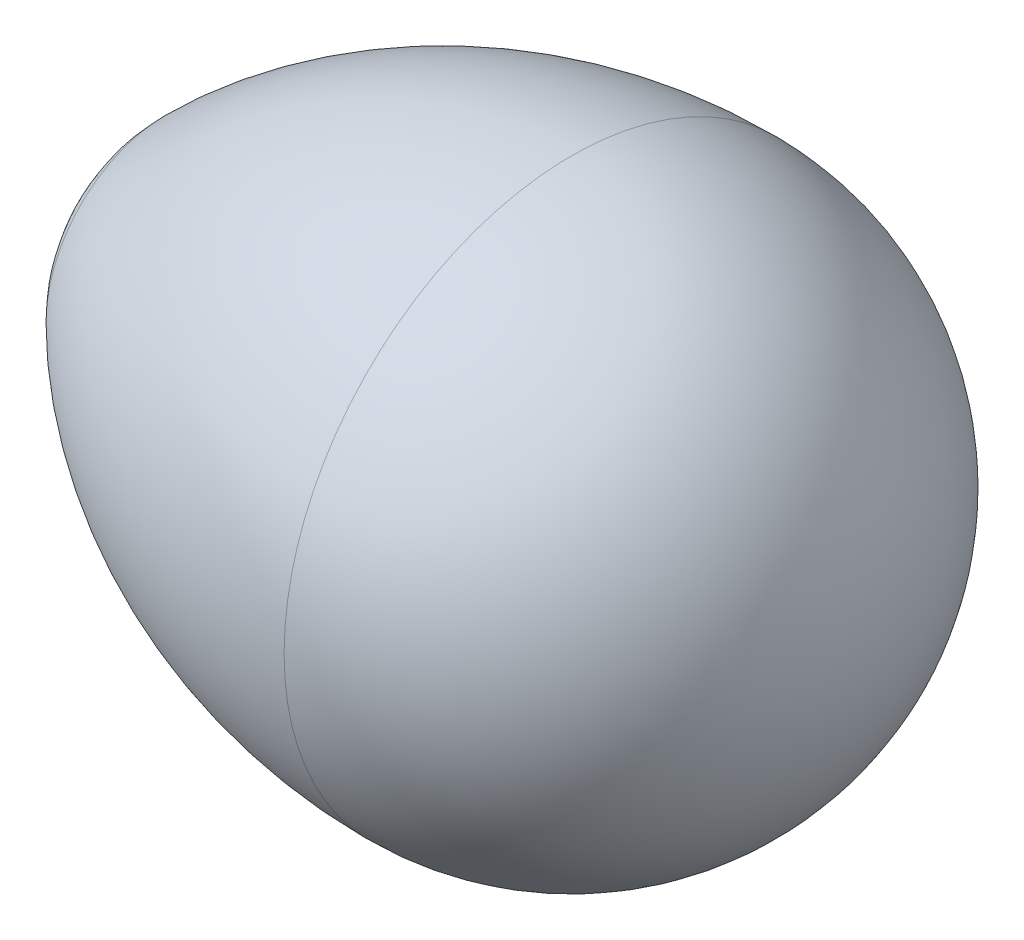
from build123d import *


with BuildPart() as part:
    # Esquisse1 → Révolution1 (revolve)
    with BuildSketch(Plane(origin=(0, 0, 0), x_dir=(1, 0, 0), z_dir=(0, 1, 0))):
        with BuildLine():
            Line((-32.32233047, 0), (0, 0))
            ThreePointArc((0, 0), (-3.661165235, 8.838834765), (-12.5, 12.5))
            ThreePointArc((-12.5, 12.5), (-22.067085809, 10.596988313), (-30.17766953, 5.17766953))
            ThreePointArc((-30.17766953, 5.17766953), (-31.764951252, 2.802134557), (-32.32233047, 0))
        make_face()
    revolve(axis=Axis((-32.32233047, 0, 0), (1, 0, 0)))


solid = part.part
